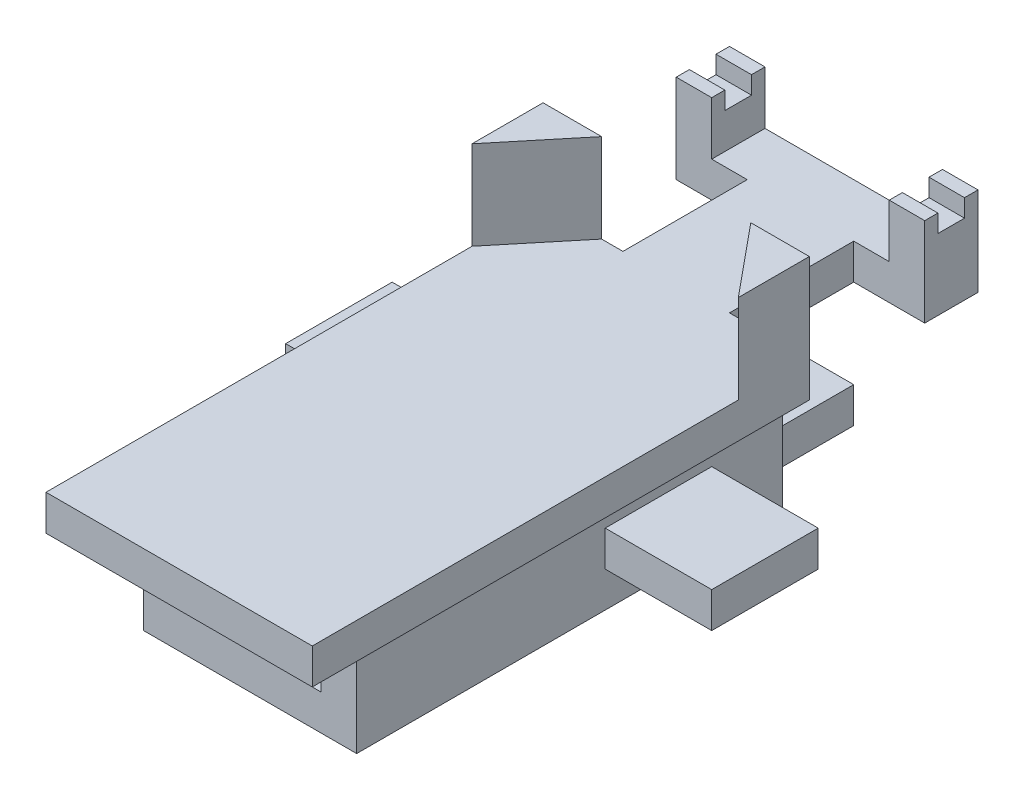
from build123d import *

# Parameters (mm, degrees)
SKETCH1_W            = 7.5
SKETCH1_H            = 10
BOSS_EXTRUDE1_DEPTH  = 1
BOSS_EXTRUDE2_DEPTH  = 2.5
SKETCH10_W           = 7.5
SKETCH10_H           = 1
BOSS_EXTRUDE5_DEPTH  = 2
SKETCH56_W           = 7.5
SKETCH56_H           = 1
BOSS_EXTRUDE17_DEPTH = 2
SKETCH57_W           = 3
SKETCH57_H           = 1
BOSS_EXTRUDE18_DEPTH = 5
SKETCH58_W           = 1.5
SKETCH58_H           = 1
BOSS_EXTRUDE19_DEPTH = 2
SKETCH59_W           = 1.5
SKETCH59_H           = 1
BOSS_EXTRUDE20_DEPTH = 2
SKETCH60_W           = 1
SKETCH60_H           = 1.5
BOSS_EXTRUDE23_DEPTH = 1.5
SKETCH61_W           = 1
SKETCH61_H           = 0.75
CUT_EXTRUDE1_DEPTH   = 0.5
SKETCH62_W           = 6
SKETCH62_H           = 12
BOSS_EXTRUDE25_DEPTH = 3
SKETCH64_W           = 4
SKETCH64_H           = 2
CUT_EXTRUDE2_DEPTH   = 12
SKETCH65_W           = 4
SKETCH65_H           = 1
BOSS_EXTRUDE26_DEPTH = 3
SKETCH66_R           = 1
CUT_EXTRUDE3_DEPTH   = 1
SKETCH67_W           = 3
SKETCH67_H           = 1
BOSS_EXTRUDE27_DEPTH = 3
SKETCH68_W           = 3
SKETCH68_H           = 1
BOSS_EXTRUDE28_DEPTH = 3


with BuildPart() as part:
    # Sketch1 → Boss-Extrude1 (new body)
    with BuildSketch(Plane(origin=(0, 0, 0), x_dir=(1, 0, 0), z_dir=(0, 1, 0))):
        Rectangle(SKETCH1_W, SKETCH1_H)
    extrude(amount=BOSS_EXTRUDE1_DEPTH)

    # Sketch2 → Boss-Extrude2 (add)
    with BuildSketch(Plane(origin=(0, 1, 0), x_dir=(1, 0, 0), z_dir=(0, 1, 0))):
        Polygon((-3.75, 3), (-2.1, 5), (-3.75, 5), align=None)
        Polygon((3.75, 5), (2.1, 5), (3.75, 3), align=None)
    extrude(amount=BOSS_EXTRUDE2_DEPTH)

    # Sketch10 → Boss-Extrude5 (add)
    with BuildSketch(Plane.XY.offset(5)):
        with Locations((0, 0.5)):
            Rectangle(SKETCH10_W, SKETCH10_H)
    extrude(amount=BOSS_EXTRUDE5_DEPTH)

    # Sketch56 → Boss-Extrude17 (add)
    with BuildSketch(Plane.XY.offset(7)):
        with Locations((0, 0.5)):
            Rectangle(SKETCH56_W, SKETCH56_H)
    extrude(amount=BOSS_EXTRUDE17_DEPTH)

    # Sketch57 → Boss-Extrude18 (add)
    with BuildSketch(Plane(origin=(0, 0, -5), x_dir=(-1, 0, 0), z_dir=(0, 0, -1))):
        with Locations((0, 0.5)):
            Rectangle(SKETCH57_W, SKETCH57_H)
    extrude(amount=BOSS_EXTRUDE18_DEPTH)

    # Sketch58 → Boss-Extrude19 (add)
    with BuildSketch(Plane(origin=(1.5, 0, 0), x_dir=(0, 0, -1), z_dir=(1, 0, 0))):
        with Locations((9.25, 0.5)):
            Rectangle(SKETCH58_W, SKETCH58_H)
    extrude(amount=BOSS_EXTRUDE19_DEPTH)

    # Sketch59 → Boss-Extrude20 (add)
    with BuildSketch(Plane.ZY.offset(1.5)):
        with Locations((-9.25, 0.5)):
            Rectangle(SKETCH59_W, SKETCH59_H)
    extrude(amount=BOSS_EXTRUDE20_DEPTH)

    # Sketch60 → Boss-Extrude23 (add)
    with BuildSketch(Plane(origin=(0, 1, 0), x_dir=(1, 0, 0), z_dir=(0, 1, 0))):
        with Locations((3, 9.25)):
            Rectangle(SKETCH60_W, SKETCH60_H)
        with Locations((-3, 9.25)):
            Rectangle(SKETCH60_W, SKETCH60_H)
    extrude(amount=BOSS_EXTRUDE23_DEPTH)

    # Sketch61 → Cut-Extrude1 (cut)
    with BuildSketch(Plane(origin=(0, 2.5, 0), x_dir=(1, 0, 0), z_dir=(0, 1, 0))):
        with Locations((-3, 9.245443114)):
            Rectangle(SKETCH61_W, SKETCH61_H)
        with Locations((3, 9.245443114)):
            Rectangle(SKETCH61_W, SKETCH61_H)
    extrude(amount=-CUT_EXTRUDE1_DEPTH, mode=Mode.SUBTRACT)

    # Sketch62 → Boss-Extrude25 (add)
    with BuildSketch(Plane(origin=(0, 0, 0), x_dir=(-1, 0, 0), z_dir=(0, -1, 0))):
        with Locations((0, -1)):
            Rectangle(SKETCH62_W, SKETCH62_H)
    extrude(amount=BOSS_EXTRUDE25_DEPTH)

    # Sketch64 → Cut-Extrude2 (cut)
    with BuildSketch(Plane.XY.offset(7)):
        with Locations((0, -1)):
            Rectangle(SKETCH64_W, SKETCH64_H)
    extrude(amount=-CUT_EXTRUDE2_DEPTH, mode=Mode.SUBTRACT)

    # Sketch65 → Boss-Extrude26 (add)
    with BuildSketch(Plane(origin=(0, 0, -5), x_dir=(-1, 0, 0), z_dir=(0, 0, -1))):
        with Locations((0, -2.5)):
            Rectangle(SKETCH65_W, SKETCH65_H)
    extrude(amount=BOSS_EXTRUDE26_DEPTH)

    # Sketch66 → Cut-Extrude3 (cut)
    with BuildSketch(Plane(origin=(0, -3, 0), x_dir=(-1, 0, 0), z_dir=(0, -1, 0))):
        with Locations((0, -5)):
            Circle(SKETCH66_R)
        with Locations((0, 5)):
            Circle(SKETCH66_R)
    extrude(amount=-CUT_EXTRUDE3_DEPTH, mode=Mode.SUBTRACT)

    # Sketch67 → Boss-Extrude27 (add)
    with BuildSketch(Plane.ZY.offset(3)):
        with Locations((-1.5, -1.5)):
            Rectangle(SKETCH67_W, SKETCH67_H)
    extrude(amount=BOSS_EXTRUDE27_DEPTH)

    # Sketch68 → Boss-Extrude28 (add)
    with BuildSketch(Plane(origin=(3, 0, 0), x_dir=(0, 0, -1), z_dir=(1, 0, 0))):
        with Locations((1.5, -1.5)):
            Rectangle(SKETCH68_W, SKETCH68_H)
    extrude(amount=BOSS_EXTRUDE28_DEPTH)


solid = part.part
